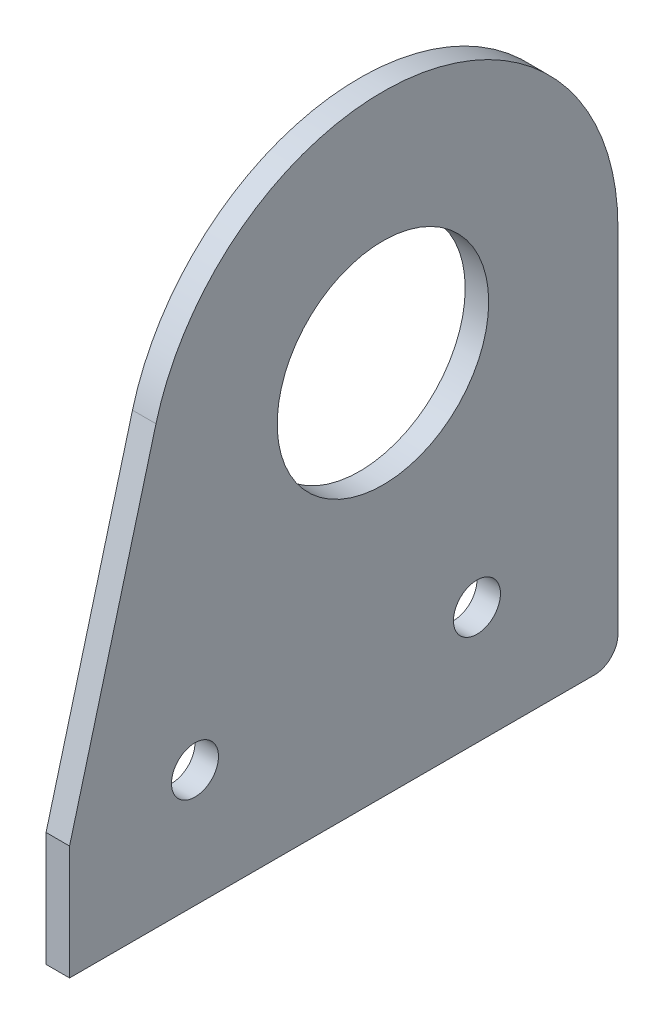
from build123d import *

# Parameters (mm, degrees)
SKETCH2_R           = 14.2875
SKETCH2_R_2         = 3.175
BOSS_EXTRUDE1_DEPTH = 3.175


with BuildPart() as part:
    # Sketch2 → Boss-Extrude1 (new body)
    with BuildSketch(Plane(origin=(0, 0, 0), x_dir=(0, 0, -1), z_dir=(1, 0, 0))):
        with BuildLine():
            Line((-30.668144985, 154.267504682), (-42.344097145, 110.692257994))
            Line((-42.344097145, 110.692257994), (-42.344097145, 95.25))
            Line((-42.344097145, 95.25), (28.575, 95.25))
            ThreePointArc((28.575, 95.25), (30.82006403, 96.17993597), (31.75, 98.425))
            Line((31.75, 98.425), (31.75, 110.608066701))
            Line((31.75, 110.608066701), (31.75, 146.05))
            ThreePointArc((31.75, 146.05), (4.144206603, 177.528374349), (-30.668144985, 154.267504682))
        make_face()
        with Locations((0, 146.05)):
            Circle(SKETCH2_R, mode=Mode.SUBTRACT)
        with Locations((-25.4, 111.125)):
            Circle(SKETCH2_R_2, mode=Mode.SUBTRACT)
        with Locations((12.7, 111.125)):
            Circle(SKETCH2_R_2, mode=Mode.SUBTRACT)
    extrude(amount=BOSS_EXTRUDE1_DEPTH)


solid = part.part
